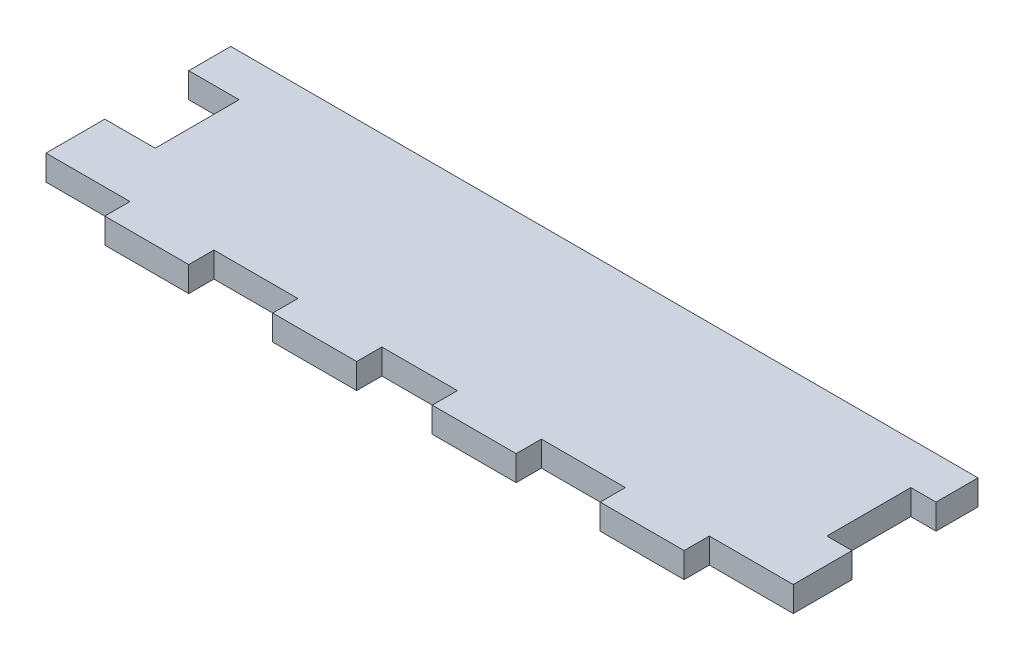
from build123d import *

# Parameters (mm, degrees)
BOSS_EXTRUDE1_DEPTH = 3


with BuildPart() as part:
    # Sketch1 → Boss-Extrude1 (new body)
    with BuildSketch(Plane(origin=(0, 0, 0), x_dir=(1, 0, 0), z_dir=(0, 1, 0))):
        Polygon((89, 17), (89, 22), (0, 22), (0, 17), (6, 17), (6, 7), (0, 7), (0, 0), (10, 0), (10, -3), (20, -3), (20, 0), (30, 0), (30, -3), (40, -3), (40, 0), (49, 0), (49, -3), (59, -3), (59, 0), (69, 0), (69, -3), (79, -3), (79, 0), (89, 0), (89, 7), (86, 7), (86, 17), align=None)
    extrude(amount=BOSS_EXTRUDE1_DEPTH)


solid = part.part
